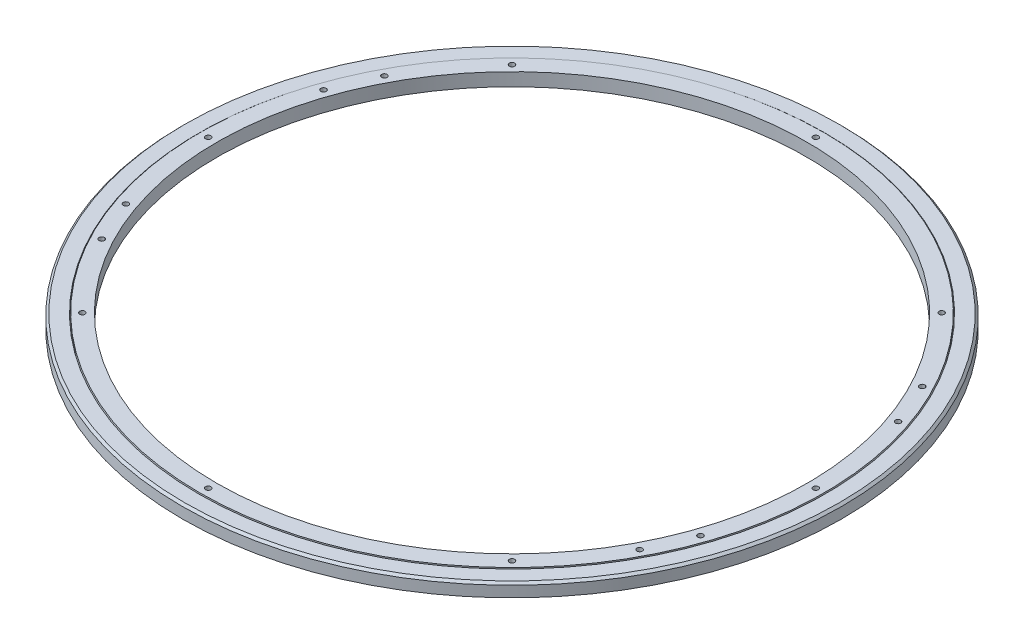
from build123d import *

# Parameters (mm, degrees)
CUT_EXTRUDE2_REACH      = 539.618
SKETCH4_R               = 3.1
CIRPATTERN2_COUNT       = 8
SKETCH9_R               = 2.35
CUT_EXTRUDE5_DEPTH      = 538.595056166
CHAMFER2_SIZE           = 2.54
CIRPATTERN7_COUNT       = 4
SKETCH17_R              = 3.1
CUT_EXTRUDE6_DEPTH      = 538.595056166
MIRROR2_COPY_1_SKETCH_R = 3.1
MIRROR2_COPY_1_DEPTH    = 538.595056166
MIRROR2_COPY_2_SKETCH_R = 3.1
MIRROR2_COPY_2_DEPTH    = 538.595056166


with BuildPart() as part:
    # Sketch1 → Revolve1 (revolve)
    with BuildSketch(Plane.XY):
        with BuildLine():
            Line((-359.6625, 0.79375), (-359.6625, -3.932441855))
            ThreePointArc((-359.6625, -3.932441855), (-356.9125, -7.14375), (-359.6625, -10.355058145))
            Line((-359.6625, -10.355058145), (-359.6625, -14.2875))
            Line((-359.6625, -14.2875), (-340.3375, -14.2875))
            Line((-340.3375, -14.2875), (-340.3375, 0.79375))
            Line((-340.3375, 0.79375), (-359.6625, 0.79375))
        make_face()
        with BuildLine():
            Line((-360.6625, 0), (-379.9875, 0))
            Line((-379.9875, 0), (-379.9875, -15.08125))
            Line((-379.9875, -15.08125), (-360.6625, -15.08125))
            Line((-360.6625, -15.08125), (-360.6625, -10.355058145))
            ThreePointArc((-360.6625, -10.355058145), (-363.4125, -7.14375), (-360.6625, -3.932441855))
            Line((-360.6625, -3.932441855), (-360.6625, 0))
        make_face()
    revolve(axis=Axis((0, 11.475820001, 0), (0, -1, 0)))

    # Sketch4 → Cut-Extrude2 (cut, up to next)
    with BuildSketch(Plane.XZ.offset(15.08125), mode=Mode.PRIVATE) as cut_extrude2_sk1:
        with Locations((0, -350.1375)):
            Circle(SKETCH4_R)
    cut_extrude2_tool1 = extrude(cut_extrude2_sk1.sketch, amount=-CUT_EXTRUDE2_REACH, mode=Mode.PRIVATE) & part.part
    cut_extrude2 = cut_extrude2_tool1.solids().sort_by_distance((0, -15.08125, -350.1375))[0]
    add(cut_extrude2, mode=Mode.SUBTRACT)

    # CirPattern2: Cut-Extrude2 ×8 about axis
    cirpattern2_axis = Axis((0, 273.21725, 0), (0, -1, 0))
    for i in range(1, CIRPATTERN2_COUNT):
        add(cut_extrude2.rotate(cirpattern2_axis, i * 360 / CIRPATTERN2_COUNT), mode=Mode.SUBTRACT)

    # Sketch9 → Cut-Extrude5 (cut, through all)
    with BuildSketch(Plane(origin=(0, 0, 0), x_dir=(-1, 0, 0), z_dir=(0, 1, 0))):
        with Locations((-323.484869815, 133.9918203)):
            Circle(SKETCH9_R)
    cut_extrude5 = extrude(amount=-CUT_EXTRUDE5_DEPTH, mode=Mode.SUBTRACT)

    # Chamfer2
    chamfer2_edges = [part.edges().sort_by_distance(p)[0] for p in [
        (379.9875, 0, 0),
    ]]
    chamfer(chamfer2_edges, length=CHAMFER2_SIZE)

    # CirPattern7: Cut-Extrude5 ×4 about axis
    cirpattern7_axis = Axis((0, 273.21725, 0), (0, -1, 0))
    for i in range(1, CIRPATTERN7_COUNT):
        add(cut_extrude5.rotate(cirpattern7_axis, i * 360 / CIRPATTERN7_COUNT), mode=Mode.SUBTRACT)

    # Sketch17 → Cut-Extrude6 (cut, symmetric)
    with BuildSketch(Plane(origin=(0, 0, 0), x_dir=(1, 0, 0), z_dir=(0, 1, 0))):
        with Locations((-309.951835339, 162.86843978)):
            Circle(SKETCH17_R)
        with Locations((-331.099210438, 113.884071554)):
            Circle(SKETCH17_R)
    cut_extrude6 = extrude(amount=CUT_EXTRUDE6_DEPTH, both=True, mode=Mode.SUBTRACT)

    # Mirror1: Cut-Extrude6 across plane
    add(cut_extrude6.mirror(Plane(origin=(0, 0, 0), x_dir=(0, 0, 1), z_dir=(1, 0, 0))), mode=Mode.SUBTRACT)

    # Mirror2 copy 1 sketch → Mirror2 copy 1 (cut, symmetric)
    with BuildSketch(Plane(origin=(0, 0, 0), x_dir=(-1, 0, 0), z_dir=(0, 1, 0))):
        with Locations((-309.951835339, 162.86843978)):
            Circle(MIRROR2_COPY_1_SKETCH_R)
        with Locations((-331.099210438, 113.884071554)):
            Circle(MIRROR2_COPY_1_SKETCH_R)
    extrude(amount=MIRROR2_COPY_1_DEPTH, both=True, mode=Mode.SUBTRACT)

    # Mirror2 copy 2 sketch → Mirror2 copy 2 (cut, symmetric)
    with BuildSketch(Plane(origin=(0, 0, 0), x_dir=(1, 0, 0), z_dir=(0, 1, 0))):
        with Locations((-309.951835339, -162.86843978)):
            Circle(MIRROR2_COPY_2_SKETCH_R)
        with Locations((-331.099210438, -113.884071554)):
            Circle(MIRROR2_COPY_2_SKETCH_R)
    extrude(amount=MIRROR2_COPY_2_DEPTH, both=True, mode=Mode.SUBTRACT)


solid = part.part
